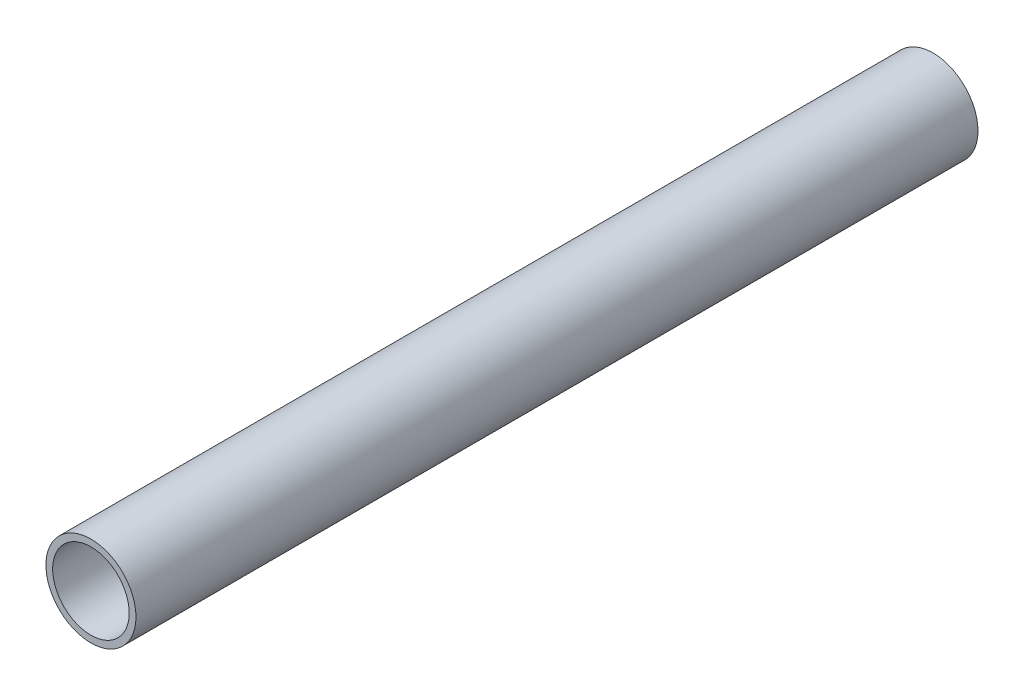
from build123d import *

# Parameters (mm, degrees)
SKETCH1_R           = 12.7
SKETCH1_R_2         = 10.795
BOSS_EXTRUDE1_DEPTH = 237.49


with BuildPart() as part:
    # Sketch1 → Boss-Extrude1 (new body)
    with BuildSketch(Plane.XY):
        Circle(SKETCH1_R)
        Circle(SKETCH1_R_2, mode=Mode.SUBTRACT)
    extrude(amount=BOSS_EXTRUDE1_DEPTH)


solid = part.part
